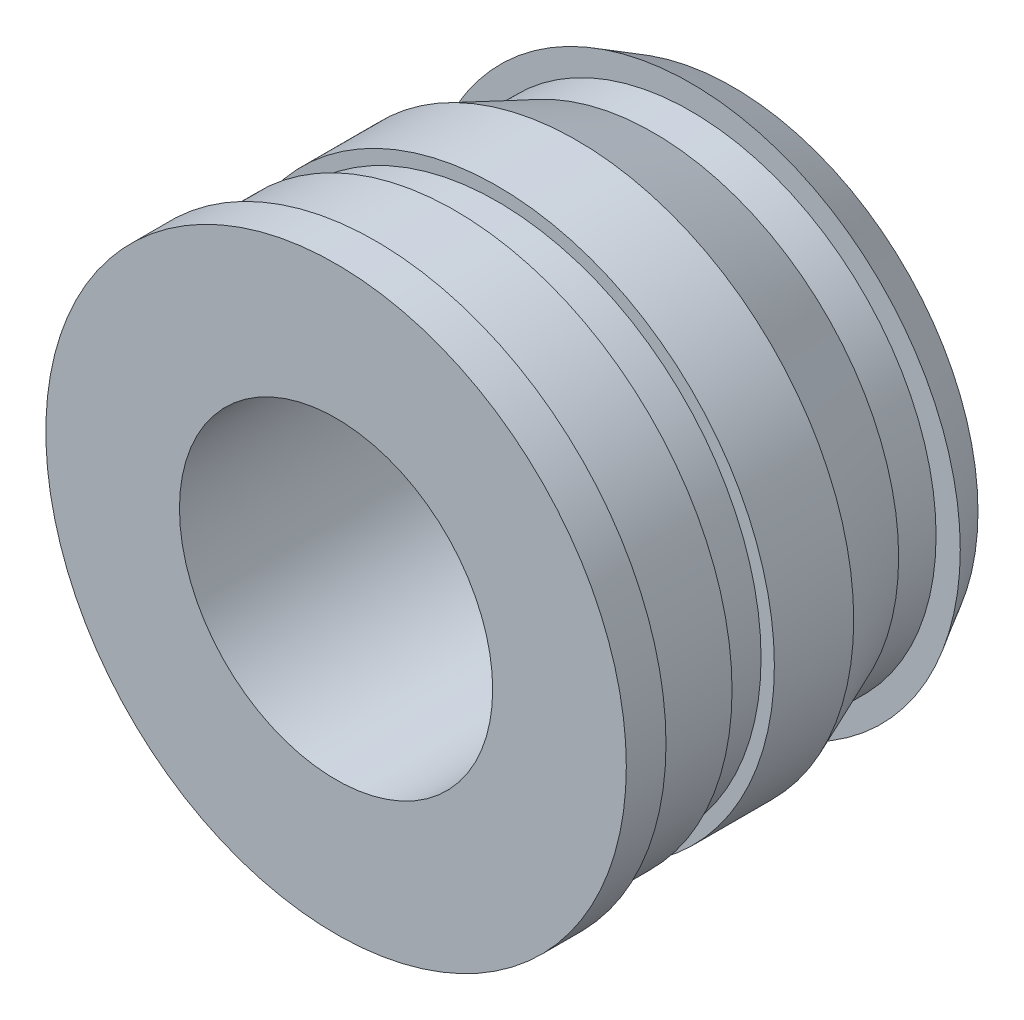
from build123d import *


with BuildPart() as part:
    # Sketch3 → Revolve1 (revolve)
    with BuildSketch(Plane(origin=(0, 0, 0), x_dir=(0, 0, -1), z_dir=(1, 0, 0))):
        Polygon((-1.9, 1.5), (-1.9, 2.78), (-1.52, 2.78), (-1.52, 2.6525), (-0.76, 2.6525), (-0.76, 2.525), (-0.354524476, 2.525), (-0.354524476, 2.6525), (0.405475524, 2.6525), (1.14, 2.34825), (1.498597225, 2.34825), (1.498597225, 2.58), (1.9, 2.34825), (1.9, 1.5), align=None)
    revolve(axis=Axis((0, 0, 1.9), (0, 0, -1)))


solid = part.part
